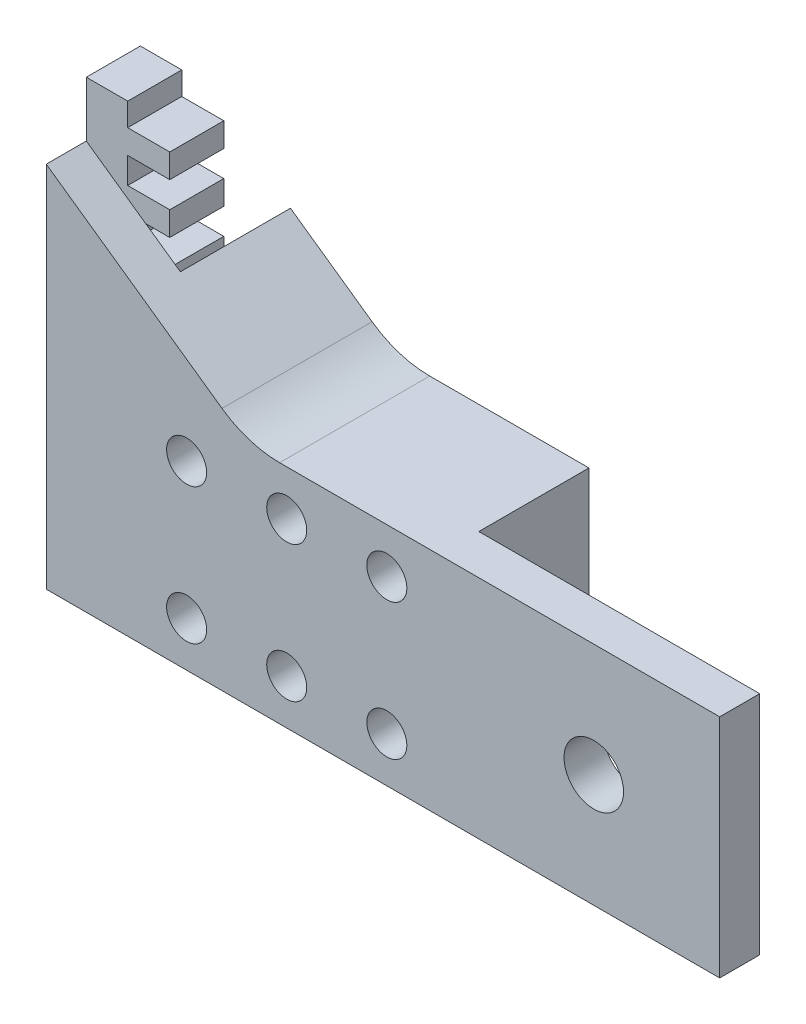
from build123d import *

# Parameters (mm, degrees)
BOSS_EXTRUDE1_DEPTH = 6.858
SKETCH3_R           = 2.54
SKETCH3_R_2         = 3.77436477
BOSS_EXTRUDE2_DEPTH = 5.08
SKETCH4_R           = 2.54
BOSS_EXTRUDE3_DEPTH = 13.97


with BuildPart() as part:
    # Sketch2 → Boss-Extrude1 (new body)
    with BuildSketch(Plane.XY):
        Polygon((11.982344641, 125.199618103), (11.982344641, 121.897618103), (17.316344641, 121.897618103), (17.316344641, 118.849618103), (11.982344641, 118.849618103), (11.982344641, 115.547618103), (17.316344641, 115.547618103), (17.316344641, 112.499618103), (11.982344641, 112.499618103), (11.982344641, 109.197618103), (17.316344641, 109.197618103), (17.316344641, 106.149618103), (11.982344641, 106.149618103), (11.982344641, 102.847618103), (17.316344641, 102.847618103), (17.316344641, 99.799618103), (11.982344641, 99.799618103), (11.982344641, 96.497618103), (6.729436841, 96.497618103), (6.729436841, 125.199618103), (6.729436841, 150.218618103), (11.982344641, 150.218618103), (11.982344641, 147.297618103), (17.316344641, 147.297618103), (17.316344641, 144.249618103), (11.982344641, 144.249618103), (11.982344641, 140.947618103), (17.316344641, 140.947618103), (17.316344641, 137.899618103), (11.982344641, 137.899618103), (11.982344641, 134.597618103), (17.316344641, 134.597618103), (17.316344641, 131.549618103), (11.982344641, 131.549618103), (11.982344641, 128.247618103), (17.316344641, 128.247618103), (17.316344641, 125.199618103), align=None)
    extrude(amount=BOSS_EXTRUDE1_DEPTH)

    # Sketch3 → Boss-Extrude2 (add)
    with BuildSketch(Plane.XY.offset(6.858)):
        with BuildLine():
            Line((6.729436841, 125.199618103), (6.729436841, 96.497618103))
            Line((6.729436841, 96.497618103), (16.3439883, 96.497618103))
            Line((16.3439883, 96.497618103), (32.312638487, 96.497618103))
            Line((32.312638487, 96.497618103), (78.23353946, 96.497618103))
            Line((78.23353946, 96.497618103), (92.175808331, 96.497618103))
            Line((92.175808331, 96.497618103), (92.175808331, 125.199618103))
            Line((92.175808331, 125.199618103), (78.23353946, 125.199618103))
            Line((78.23353946, 125.199618103), (36.33380561, 125.199618103))
            ThreePointArc((36.33380561, 125.199618103), (32.5002138, 125.792034783), (29.024272972, 127.514015924))
            Line((29.024272972, 127.514015924), (6.729436841, 143.205434636))
            Line((6.729436841, 143.205434636), (6.729436841, 125.199618103))
        make_face()
        with Locations((24.539097495, 102.212466287)):
            Circle(SKETCH3_R, mode=Mode.SUBTRACT)
        with Locations((76.2, 110.848618103)):
            Circle(SKETCH3_R_2, mode=Mode.SUBTRACT)
        with Locations((24.539097495, 119.484769918)):
            Circle(SKETCH3_R, mode=Mode.SUBTRACT)
        with Locations((37.239097495, 119.484769918)):
            Circle(SKETCH3_R, mode=Mode.SUBTRACT)
        with Locations((37.239097495, 102.212466287)):
            Circle(SKETCH3_R, mode=Mode.SUBTRACT)
        with Locations((49.939097495, 119.484769918)):
            Circle(SKETCH3_R, mode=Mode.SUBTRACT)
        with Locations((49.939097495, 102.212466287)):
            Circle(SKETCH3_R, mode=Mode.SUBTRACT)
    extrude(amount=BOSS_EXTRUDE2_DEPTH)

    # Sketch4 → Boss-Extrude3 (add)
    with BuildSketch(Plane(origin=(0, 0, 6.858), x_dir=(-1, 0, 0), z_dir=(0, 0, -1))):
        with BuildLine():
            Line((-29.024272972, 127.514015924), (-18.664038362, 134.805694511))
            Line((-18.664038362, 134.805694511), (-18.664038362, 96.497618103))
            Line((-18.664038362, 96.497618103), (-56.536837783, 96.497618103))
            Line((-56.536837783, 96.497618103), (-56.536837783, 125.199618103))
            Line((-56.536837783, 125.199618103), (-36.33380561, 125.199618103))
            ThreePointArc((-36.33380561, 125.199618103), (-32.5002138, 125.792034783), (-29.024272972, 127.514015924))
        make_face()
        with Locations((-49.939097495, 102.212466287)):
            Circle(SKETCH4_R, mode=Mode.SUBTRACT)
        with Locations((-37.239097495, 102.212466287)):
            Circle(SKETCH4_R, mode=Mode.SUBTRACT)
        with Locations((-24.539097495, 102.212466287)):
            Circle(SKETCH4_R, mode=Mode.SUBTRACT)
        with Locations((-24.539097495, 119.484769918)):
            Circle(SKETCH4_R, mode=Mode.SUBTRACT)
        with Locations((-37.239097495, 119.484769918)):
            Circle(SKETCH4_R, mode=Mode.SUBTRACT)
        with Locations((-49.939097495, 119.484769918)):
            Circle(SKETCH4_R, mode=Mode.SUBTRACT)
    extrude(amount=BOSS_EXTRUDE3_DEPTH)


solid = part.part
